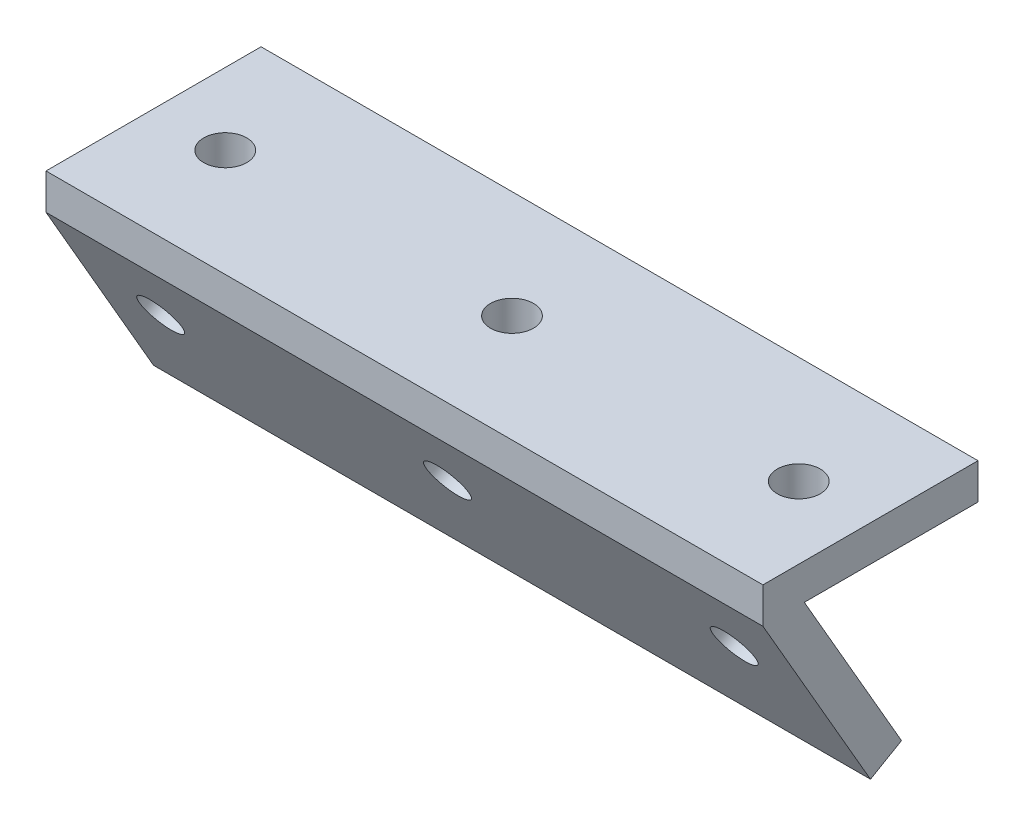
from build123d import *

# Parameters (mm, degrees)
BOSS_EXTRUDE1_START = -0.0001
SKETCH2_W           = 100
SKETCH2_H           = 30
BOSS_EXTRUDE1_DEPTH = 5.0001
CIRPATTERN1_COUNT   = 2
CIRPATTERN1_ANGLE   = 60
SKETCH4_R           = 3
CUT_EXTRUDE1_DEPTH  = 10
SKETCH5_R           = 3
CUT_EXTRUDE2_DEPTH  = 10


with BuildPart() as part:
    # Sketch2 → Boss-Extrude1 (new body)
    with BuildSketch(Plane(origin=(0, 0, 0), x_dir=(1, 0, 0), z_dir=(0, 1, 0)).offset(BOSS_EXTRUDE1_START)):
        Rectangle(SKETCH2_W, SKETCH2_H)
    boss_extrude1 = extrude(amount=BOSS_EXTRUDE1_DEPTH)

    # CirPattern1: Boss-Extrude1 ×2 about axis
    cirpattern1_axis = Axis((0, -0.0001, 15), (-1, 0, 0))
    for i in range(1, CIRPATTERN1_COUNT):
        add(boss_extrude1.rotate(cirpattern1_axis, i * CIRPATTERN1_ANGLE / (CIRPATTERN1_COUNT - 1)))

    # Sketch4 → Cut-Extrude1 (cut)
    with BuildSketch(Plane.XZ.offset(0.0001)):
        Circle(SKETCH4_R)
        with Locations((40, 0)):
            Circle(SKETCH4_R)
        with Locations((-40, 0)):
            Circle(SKETCH4_R)
    extrude(amount=-CUT_EXTRUDE1_DEPTH, mode=Mode.SUBTRACT)

    # Sketch5 → Cut-Extrude2 (cut)
    with BuildSketch(Plane(origin=(0, -6.495215528, 11.250043301), x_dir=(1, 0, 0), z_dir=(0, -0.5, 0.866025404))):
        with Locations((40, -4.500086603)):
            Circle(SKETCH5_R)
        with Locations((0, -4.500086603)):
            Circle(SKETCH5_R)
        with Locations((-40, -4.500086603)):
            Circle(SKETCH5_R)
    extrude(amount=-CUT_EXTRUDE2_DEPTH, mode=Mode.SUBTRACT)


solid = part.part
